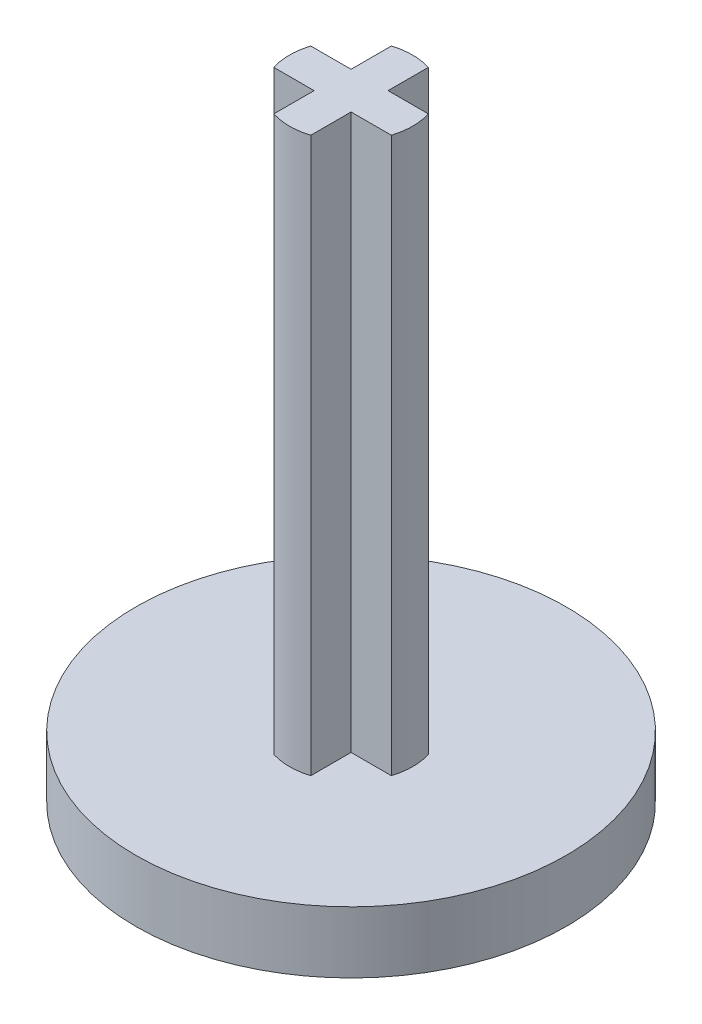
from build123d import *

# Parameters (mm, degrees)
SKETCH1_R               = 17.4625
BOSS_EXTRUDE1_DEPTH     = 5
BOSS_EXTRUDE2_START     = 127
SKETCH1_2_R             = 17.4625
BOSS_EXTRUDE2_DEPTH     = 5
BOSS_EXTRUDE3_DEPTH     = 122
SKETCH3_W               = 34.925
SKETCH3_H               = 82
CUT_EXTRUDE1_DEPTH      = 18.4625
CUT_EXTRUDE1_DEPTH_BACK = 18.4625


with BuildPart() as part:
    # Sketch1 → Boss-Extrude1 (new body)
    with BuildSketch(Plane(origin=(0, 0, 0), x_dir=(1, 0, 0), z_dir=(0, 1, 0))):
        Circle(SKETCH1_R)
    extrude(amount=BOSS_EXTRUDE1_DEPTH)



with BuildPart() as body_2:
    # Sketch1_2 → Boss-Extrude2 (new body)
    with BuildSketch(Plane(origin=(0, 0, 0), x_dir=(1, 0, 0), z_dir=(0, 1, 0)).offset(BOSS_EXTRUDE2_START)):
        Circle(SKETCH1_2_R)
    extrude(amount=BOSS_EXTRUDE2_DEPTH)


with BuildPart() as part_1:
    add(part.part)

    add(body_2.part)  # Boss-Extrude3 merges body 2
    # Sketch2 → Boss-Extrude3 (add)
    with BuildSketch(Plane(origin=(0, 5, 0), x_dir=(1, 0, 0), z_dir=(0, 1, 0))):
        with BuildLine():
            Line((-4.769696007, -1.5), (-1.5, -1.5))
            Line((-1.5, -1.5), (-1.5, -4.769696007))
            ThreePointArc((-1.5, -4.769696007), (0, -5), (1.5, -4.769696007))
            Line((1.5, -4.769696007), (1.5, -1.5))
            Line((1.5, -1.5), (4.769696007, -1.5))
            ThreePointArc((4.769696007, -1.5), (5, 0), (4.769696007, 1.5))
            Line((4.769696007, 1.5), (1.5, 1.5))
            Line((1.5, 1.5), (1.5, 4.769696007))
            ThreePointArc((1.5, 4.769696007), (0, 5), (-1.5, 4.769696007))
            Line((-1.5, 4.769696007), (-1.5, 1.5))
            Line((-1.5, 1.5), (-4.769696007, 1.5))
            ThreePointArc((-4.769696007, 1.5), (-5, 0), (-4.769696007, -1.5))
        make_face()
    extrude(amount=BOSS_EXTRUDE3_DEPTH)

    # Sketch3 → Cut-Extrude1 (cut, two sides)
    with BuildSketch(Plane.XY) as cut_extrude1_sk:
        with Locations((0, 91)):
            Rectangle(SKETCH3_W, SKETCH3_H)
    extrude(amount=CUT_EXTRUDE1_DEPTH, mode=Mode.SUBTRACT)
    extrude(cut_extrude1_sk.sketch, amount=-CUT_EXTRUDE1_DEPTH_BACK, mode=Mode.SUBTRACT)


solid = part_1.part
